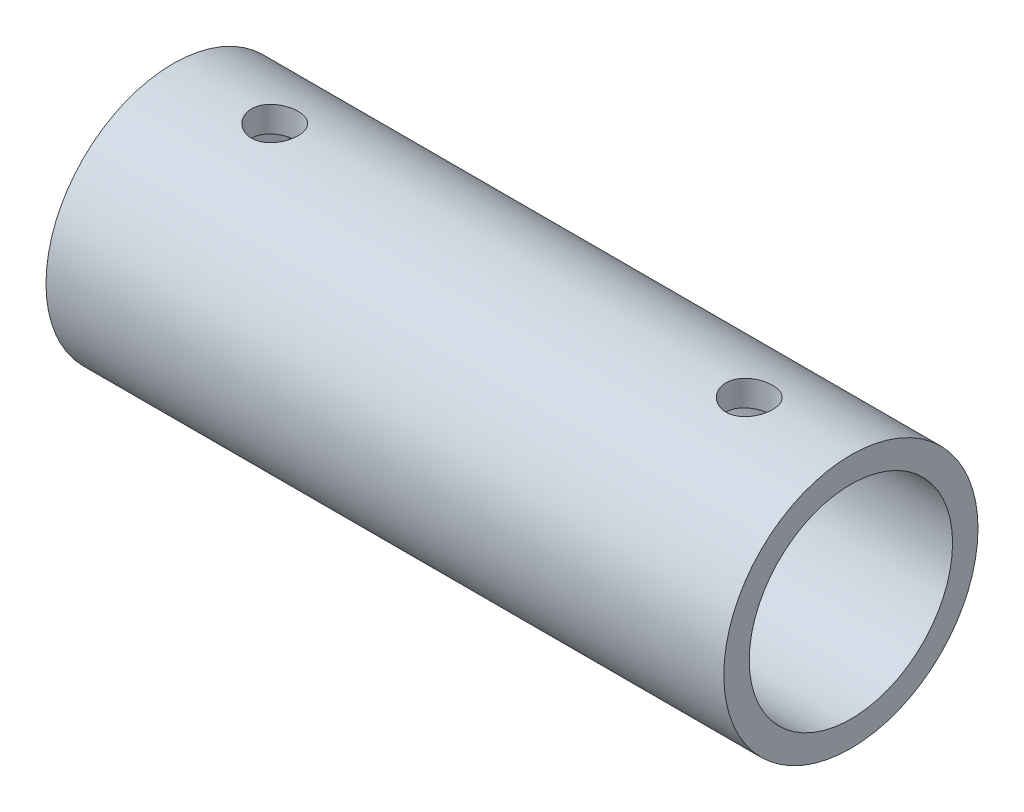
from build123d import *

# Parameters (mm, degrees)
F_3_4_16_TAPPED_HOLE1_REACH  = 167.74
F_3_4_16_TAPPED_HOLE1_BORE_R = 8.73125


with BuildPart() as part:
    # Sketch1 → Revolve1 (revolve)
    with BuildSketch(Plane.XY, mode=Mode.PRIVATE) as revolve1_sk:
        Polygon((-127, 0), (-127, 47.625), (127, 47.625), (127, 38.1), (-120.65, 38.1), (-120.65, 0), align=None)
    revolve(revolve1_sk.sketch.rotate(Axis((-127, 0, 0), (1, 0, 0)), 90), axis=Axis((-127, 0, 0), (1, 0, 0)))

    # 3/4-16 Tapped Hole1 bore → 3/4-16 Tapped Hole1 (cut, up to next)
    with BuildSketch(Plane(origin=(0, 47.625, 0), x_dir=(1, 0, 0), z_dir=(0, 1, 0)), mode=Mode.PRIVATE) as f_3_4_16_tapped_hole1_sk1:
        with Locations((-88.9, 0)):
            Circle(F_3_4_16_TAPPED_HOLE1_BORE_R)
    f_3_4_16_tapped_hole1_tool1 = extrude(f_3_4_16_tapped_hole1_sk1.sketch, amount=-F_3_4_16_TAPPED_HOLE1_REACH, mode=Mode.PRIVATE) & part.part
    # 3/4-16 Tapped Hole1 bore → 3/4-16 Tapped Hole1 (cut, up to next)
    with BuildSketch(Plane(origin=(0, 47.625, 0), x_dir=(1, 0, 0), z_dir=(0, 1, 0)), mode=Mode.PRIVATE) as f_3_4_16_tapped_hole1_sk2:
        with Locations((88.9, 0)):
            Circle(F_3_4_16_TAPPED_HOLE1_BORE_R)
    f_3_4_16_tapped_hole1_tool2 = extrude(f_3_4_16_tapped_hole1_sk2.sketch, amount=-F_3_4_16_TAPPED_HOLE1_REACH, mode=Mode.PRIVATE) & part.part
    add(f_3_4_16_tapped_hole1_tool1.solids().sort_by_distance((-88.9, 47.625, 0))[0], mode=Mode.SUBTRACT)
    add(f_3_4_16_tapped_hole1_tool2.solids().sort_by_distance((88.9, 47.625, 0))[0], mode=Mode.SUBTRACT)


solid = part.part
